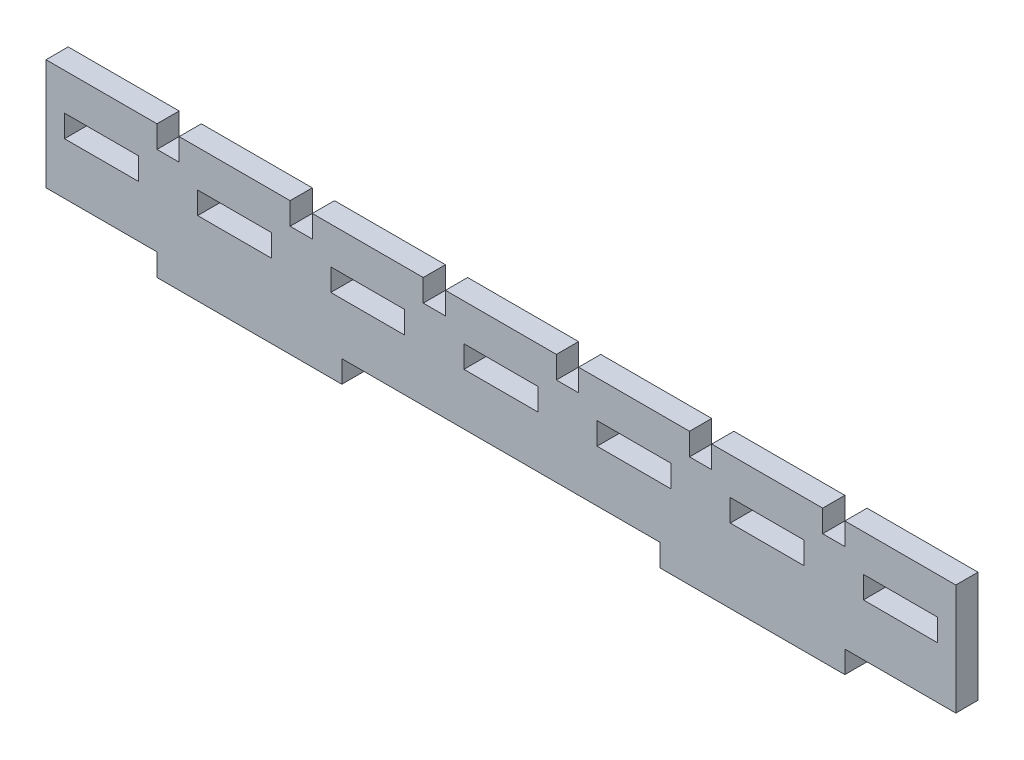
from build123d import *

# Parameters (mm, degrees)
SKETCH2_W           = 10
SKETCH2_H           = 3
BOSS_EXTRUDE2_DEPTH = 3


with BuildPart() as part:
    # Sketch2 → Boss-Extrude2 (new body)
    with BuildSketch(Plane.XY):
        Polygon((-43.5, 7.5), (-28.5, 7.5), (-28.5, 4.5), (-25.5, 4.5), (-25.5, 7.5), (-10.5, 7.5), (-10.5, 4.5), (-7.5, 4.5), (-7.5, 7.5), (7.5, 7.5), (7.5, 4.5), (10.5, 4.5), (10.5, 7.5), (25.5, 7.5), (25.5, 4.5), (28.5, 4.5), (28.5, 7.5), (43.5, 7.5), (43.5, 4.5), (46.5, 4.5), (46.5, 7.5), (61.5, 7.5), (61.5, -7.5), (46.5, -7.5), (46.5, -10.5), (21.5, -10.5), (21.5, -7.5), (10, -7.5), (-10, -7.5), (-21.5, -7.5), (-21.5, -10.5), (-46.5, -10.5), (-46.5, -7.5), (-61.5, -7.5), (-61.5, 7.5), (-46.5, 7.5), (-46.5, 4.5), (-43.5, 4.5), align=None)
        with Locations((-54, 1)):
            Rectangle(SKETCH2_W, SKETCH2_H, mode=Mode.SUBTRACT)
        with Locations((-36, 1)):
            Rectangle(SKETCH2_W, SKETCH2_H, mode=Mode.SUBTRACT)
        with Locations((-18, 1)):
            Rectangle(SKETCH2_W, SKETCH2_H, mode=Mode.SUBTRACT)
        with Locations((0, 1)):
            Rectangle(SKETCH2_W, SKETCH2_H, mode=Mode.SUBTRACT)
        with Locations((18, 1)):
            Rectangle(SKETCH2_W, SKETCH2_H, mode=Mode.SUBTRACT)
        with Locations((36, 1)):
            Rectangle(SKETCH2_W, SKETCH2_H, mode=Mode.SUBTRACT)
        with Locations((54, 1)):
            Rectangle(SKETCH2_W, SKETCH2_H, mode=Mode.SUBTRACT)
    extrude(amount=BOSS_EXTRUDE2_DEPTH)


solid = part.part
